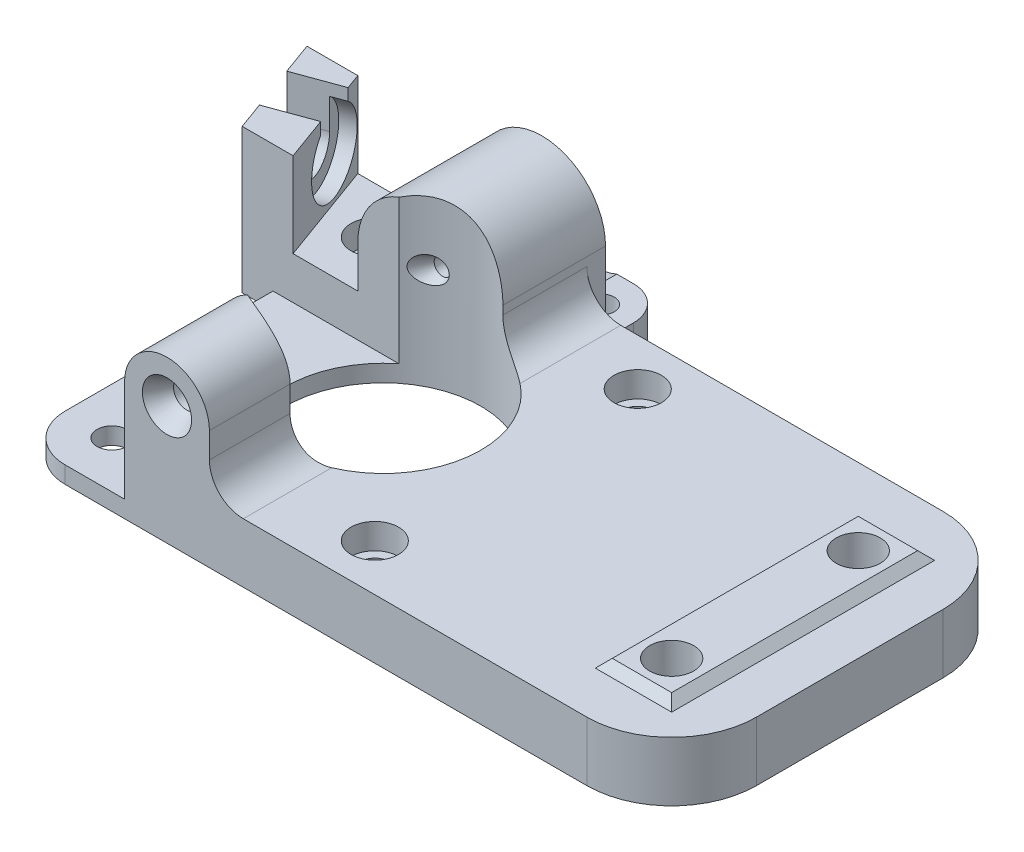
from build123d import *

# Parameters (mm, degrees)
SKETCH1_W                = 77
SKETCH1_H                = 42
BOSS_EXTRUDE1_DEPTH      = 7
FILLET1_R                = 10
FILLET2_R                = 10
FILLET3_R                = 5.5
SKETCH2_W                = 9
SKETCH2_H                = 31
BOSS_EXTRUDE2_DEPTH      = 1
CUT_EXTRUDE1_DEPTH       = 11
CUT_EXTRUDE2_DEPTH       = 31
SKETCH5_R                = 2.6
CUT_EXTRUDE3_DEPTH       = 6
SKETCH6_R                = 2.8
CUT_EXTRUDE4_DEPTH       = 3
SKETCH7_R                = 1.75
CUT_EXTRUDE5_DEPTH       = 4
SKETCH8_W                = 14.5
SKETCH8_H                = 30
CUT_EXTRUDE6_DEPTH       = 5
BOSS_EXTRUDE3_DEPTH      = 11.5
BOSS_EXTRUDE4_DEPTH      = 4
BOSS_EXTRUDE5_DEPTH      = 14.2
FILLET4_R                = 4
FILLET5_R                = 4
SKETCH12_R               = 11.5
CUT_EXTRUDE7_DEPTH       = 14
CUT_EXTRUDE7_DEPTH_BACK  = 14
SKETCH13_W               = 6.185296294
SKETCH13_H               = 18.5
CUT_EXTRUDE8_DEPTH       = 14
BOSS_EXTRUDE6_DEPTH      = 10
BOSS_EXTRUDE6_DEPTH_BACK = 7
CUT_EXTRUDE9_DEPTH       = 10
SKETCH16_R               = 4.85
CUT_EXTRUDE10_DEPTH      = 10
SKETCH17_R               = 1
CUT_EXTRUDE11_DEPTH      = 5
SKETCH19_R               = 2.8
CUT_EXTRUDE12_DEPTH      = 3
SKETCH20_R               = 1.75
CUT_EXTRUDE13_DEPTH      = 8
SKETCH21_R               = 4.5
CUT_EXTRUDE14_DEPTH      = 1.7
CUT_EXTRUDE15_DEPTH      = 1.7
CUT_EXTRUDE15_DEPTH_BACK = 31.7
SKETCH23_R               = 1.75
CUT_EXTRUDE16_DEPTH      = 50.7
SKETCH24_R               = 2.9
CUT_EXTRUDE17_DEPTH      = 2.325
CUT_EXTRUDE17_TAPER      = 30
CUT_EXTRUDE18_REACH      = 49.675
SKETCH25_R               = 1.557660624
SKETCH26_R               = 7
CUT_EXTRUDE19_DEPTH      = 5.8
SKETCH27_R               = 1.5
CUT_EXTRUDE20_DEPTH      = 5.0000001
SKETCH29_R               = 5
CUT_EXTRUDE21_DEPTH      = 2
MIRROR5_COPY_1_SKETCH_R  = 2.6
MIRROR5_COPY_1_DEPTH     = 6
MIRROR5_COPY_2_SKETCH_R  = 2.6
MIRROR5_COPY_2_DEPTH     = 6
SKETCH35_R               = 1
CUT_EXTRUDE23_DEPTH      = 2.3
CUT_EXTRUDE23_TAPER      = -28


with BuildPart() as part:
    # Sketch1 → Boss-Extrude1 (new body)
    with BuildSketch(Plane(origin=(0, 0, 0), x_dir=(1, 0, 0), z_dir=(0, 1, 0))):
        with Locations((38.5, 21)):
            Rectangle(SKETCH1_W, SKETCH1_H)
    extrude(amount=BOSS_EXTRUDE1_DEPTH)

    # Fillet1
    fillet1_edges = [part.edges().sort_by_distance(p)[0] for p in [
        (77, 3.5, 0),
    ]]
    fillet(fillet1_edges, radius=FILLET1_R)

    # Fillet2
    fillet2_edges = [part.edges().sort_by_distance(p)[0] for p in [
        (77, 3.5, -42),
    ]]
    fillet(fillet2_edges, radius=FILLET2_R)

    # Fillet3
    fillet3_edges = [part.edges().sort_by_distance(p)[0] for p in [
        (0, 3.5, 0),
    ]]
    fillet(fillet3_edges, radius=FILLET3_R)

    # Sketch2 → Boss-Extrude2 (add)
    with BuildSketch(Plane(origin=(0, 7, 0), x_dir=(1, 0, 0), z_dir=(0, 1, 0))):
        with Locations((67, 21)):
            Rectangle(SKETCH2_W, SKETCH2_H)
    extrude(amount=BOSS_EXTRUDE2_DEPTH)

    # Sketch3 → Cut-Extrude1 (cut)
    with BuildSketch(Plane(origin=(71.5, 0, 0), x_dir=(0, 0, -1), z_dir=(1, 0, 0))):
        Polygon((5.5, 7), (5.5, 8), (6.5, 8), align=None)
    cut_extrude1 = extrude(amount=-CUT_EXTRUDE1_DEPTH, mode=Mode.SUBTRACT)

    # Sketch4 → Cut-Extrude2 (cut)
    with BuildSketch(Plane(origin=(0, 0, -36.5), x_dir=(-1, 0, 0), z_dir=(0, 0, -1))):
        Polygon((-71.5, 8), (-70.5, 8), (-71.5, 7), align=None)
        Polygon((-62.5, 8), (-62.5, 7), (-63.5, 8), align=None)
    extrude(amount=-CUT_EXTRUDE2_DEPTH, mode=Mode.SUBTRACT)

    # Mirror2: Cut-Extrude1 across plane
    add(cut_extrude1.mirror(Plane.XY.offset(-21)), mode=Mode.SUBTRACT)

    # Sketch5 → Cut-Extrude3 (cut)
    with BuildSketch(Plane(origin=(0, 8, 0), x_dir=(1, 0, 0), z_dir=(0, 1, 0))):
        with Locations((67, 10)):
            Circle(SKETCH5_R)
    cut_extrude3 = extrude(amount=-CUT_EXTRUDE3_DEPTH, mode=Mode.SUBTRACT)

    # Mirror3: Cut-Extrude3 across plane
    add(cut_extrude3.mirror(Plane.XY.offset(-21)), mode=Mode.SUBTRACT)

    # Sketch6 → Cut-Extrude4 (cut)
    with BuildSketch(Plane(origin=(0, 7, 0), x_dir=(1, 0, 0), z_dir=(0, 1, 0))):
        with Locations((36.5, 5.5)):
            Circle(SKETCH6_R)
    cut_extrude4 = extrude(amount=-CUT_EXTRUDE4_DEPTH, mode=Mode.SUBTRACT)

    # Sketch7 → Cut-Extrude5 (cut)
    with BuildSketch(Plane(origin=(0, 4, 0), x_dir=(1, 0, 0), z_dir=(0, 1, 0))):
        with Locations((36.5, 5.5)):
            Circle(SKETCH7_R)
    cut_extrude5 = extrude(amount=-CUT_EXTRUDE5_DEPTH, mode=Mode.SUBTRACT)

    # Mirror4: Cut-Extrude4, Cut-Extrude5 across plane
    add(cut_extrude4.mirror(Plane.XY.offset(-21)), mode=Mode.SUBTRACT)
    add(cut_extrude5.mirror(Plane.XY.offset(-21)), mode=Mode.SUBTRACT)

    # Sketch8 → Cut-Extrude6 (cut)
    with BuildSketch(Plane(origin=(0, 7, 0), x_dir=(1, 0, 0), z_dir=(0, 1, 0))):
        with Locations((7.25, 15)):
            Rectangle(SKETCH8_W, SKETCH8_H)
    extrude(amount=-CUT_EXTRUDE6_DEPTH, mode=Mode.SUBTRACT)

    # Sketch9 → Boss-Extrude3 (add)
    with BuildSketch(Plane.XY):
        with BuildLine():
            Line((12.5, 2), (12.5, 14))
            ThreePointArc((12.5, 14), (17.5, 19), (22.5, 14))
            Line((22.5, 14), (22.5, 7))
            Line((22.5, 7), (14.5, 7))
            Line((14.5, 7), (14.5, 2))
            Line((14.5, 2), (12.5, 2))
        make_face()
    extrude(amount=-BOSS_EXTRUDE3_DEPTH)

    # Sketch10 → Boss-Extrude4 (add)
    with BuildSketch(Plane.XZ):
        with BuildLine():
            Line((26.5, -42), (26.5, -46))
            ThreePointArc((26.5, -46), (25.328427125, -48.828427125), (22.5, -50))
            Line((22.5, -50), (12.5, -50))
            ThreePointArc((12.5, -50), (9.671572875, -48.828427125), (8.5, -46))
            Line((8.5, -46), (8.5, -42))
            Line((8.5, -42), (26.5, -42))
        make_face()
    extrude(amount=-BOSS_EXTRUDE4_DEPTH)

    # Sketch11 → Boss-Extrude5 (add)
    with BuildSketch(Plane(origin=(0, 0, -44.2), x_dir=(-1, 0, 0), z_dir=(0, 0, -1))):
        with BuildLine():
            Line((-25, 4), (-25, 12))
            ThreePointArc((-25, 12), (-17.5, 19.5), (-10, 12))
            Line((-10, 12), (-10, 4))
            Line((-10, 4), (-25, 4))
        make_face()
    extrude(amount=-BOSS_EXTRUDE5_DEPTH)

    # Fillet4
    fillet4_edges = [part.edges().sort_by_distance(p)[0] for p in [
        (22.5, 7, -5.75),
    ]]
    fillet(fillet4_edges, radius=FILLET4_R)

    # Fillet5
    fillet5_edges = [part.edges().sort_by_distance(p)[0] for p in [
        (25, 7, -36),
    ]]
    fillet(fillet5_edges, radius=FILLET5_R)

    # Sketch12 → Cut-Extrude7 (cut, two sides)
    with BuildSketch(Plane(origin=(0, 7, 0), x_dir=(1, 0, 0), z_dir=(0, 1, 0))) as cut_extrude7_sk:
        with Locations((22, 21)):
            Circle(SKETCH12_R)
    extrude(amount=CUT_EXTRUDE7_DEPTH, mode=Mode.SUBTRACT)
    extrude(cut_extrude7_sk.sketch, amount=-CUT_EXTRUDE7_DEPTH_BACK, mode=Mode.SUBTRACT)

    # Sketch13 → Cut-Extrude8 (cut)
    with BuildSketch(Plane(origin=(0, 2, 0), x_dir=(1, 0, 0), z_dir=(0, 1, 0))):
        with Locations((14.723239075, 20.75)):
            Rectangle(SKETCH13_W, SKETCH13_H)
    extrude(amount=CUT_EXTRUDE8_DEPTH, mode=Mode.SUBTRACT)

    # Sketch14 → Boss-Extrude6 (add, two sides)
    with BuildSketch(Plane(origin=(0, 7, 0), x_dir=(1, 0, 0), z_dir=(0, 1, 0))) as boss_extrude6_sk:
        Polygon((10, 42), (-8, 42), (-3.632357189, 30), (10, 30), align=None)
    extrude(amount=BOSS_EXTRUDE6_DEPTH)
    extrude(boss_extrude6_sk.sketch, amount=-BOSS_EXTRUDE6_DEPTH_BACK)

    # Sketch15 → Cut-Extrude9 (cut)
    with BuildSketch(Plane(origin=(0, 17, 0), x_dir=(1, 0, 0), z_dir=(0, 1, 0))):
        Polygon((10, 42), (10, 30), (2.367642811, 30), (-2, 42), align=None)
    extrude(amount=-CUT_EXTRUDE9_DEPTH, mode=Mode.SUBTRACT)

    # Sketch16 → Cut-Extrude10 (cut)
    with BuildSketch(Plane(origin=(0, 0, -44.2), x_dir=(-1, 0, 0), z_dir=(0, 0, -1))):
        with Locations((-17.5, 12)):
            Circle(SKETCH16_R)
    extrude(amount=-CUT_EXTRUDE10_DEPTH, mode=Mode.SUBTRACT)

    # Sketch17 → Cut-Extrude11 (cut)
    with BuildSketch(Plane(origin=(0, 0, -34.2), x_dir=(-1, 0, 0), z_dir=(0, 0, -1))):
        with Locations((-17.5, 12)):
            Circle(SKETCH17_R)
    extrude(amount=-CUT_EXTRUDE11_DEPTH, mode=Mode.SUBTRACT)

    # Sketch19 → Cut-Extrude12 (cut)
    with BuildSketch(Plane(origin=(0, 7, 0), x_dir=(1, 0, 0), z_dir=(0, 1, 0))):
        with Locations((5.5, 36.5)):
            Circle(SKETCH19_R)
    extrude(amount=-CUT_EXTRUDE12_DEPTH, mode=Mode.SUBTRACT)

    # Sketch20 → Cut-Extrude13 (cut)
    with BuildSketch(Plane(origin=(0, 4, 0), x_dir=(1, 0, 0), z_dir=(0, 1, 0))):
        with Locations((5.5, 36.5)):
            Circle(SKETCH20_R)
    extrude(amount=-CUT_EXTRUDE13_DEPTH, mode=Mode.SUBTRACT)

    # Sketch21 → Cut-Extrude14 (cut)
    with BuildSketch(Plane(origin=(11.73249536, 0, -4.270279085), x_dir=(-0.342020143, 0, -0.939692621), z_dir=(0.939692621, 0, -0.342020143))):
        with Locations((35.53099709, 12)):
            Circle(SKETCH21_R)
    extrude(amount=-CUT_EXTRUDE14_DEPTH, mode=Mode.SUBTRACT)

    # Sketch22 → Cut-Extrude15 (cut, two sides)
    with BuildSketch(Plane(origin=(10.135017905, 0, -3.688844841), x_dir=(-0.342020143, 0, -0.939692621), z_dir=(0.939692621, 0, -0.342020143))) as cut_extrude15_sk:
        with BuildLine():
            Line((32.83099709, 12), (32.83099709, 17))
            Line((32.83099709, 17), (38.23099709, 17))
            Line((38.23099709, 17), (38.23099709, 12))
            ThreePointArc((38.23099709, 12), (35.53099709, 9.3), (32.83099709, 12))
        make_face()
    extrude(amount=CUT_EXTRUDE15_DEPTH, mode=Mode.SUBTRACT)
    extrude(cut_extrude15_sk.sketch, amount=-CUT_EXTRUDE15_DEPTH_BACK, mode=Mode.SUBTRACT)

    # Sketch23 → Cut-Extrude16 (cut)
    with BuildSketch(Plane(origin=(0, 2, 0), x_dir=(1, 0, 0), z_dir=(0, 1, 0))):
        with Locations((5.5, 5.5)):
            Circle(SKETCH23_R)
    extrude(amount=-CUT_EXTRUDE16_DEPTH, mode=Mode.SUBTRACT)

    # Sketch24 → Cut-Extrude17 (cut)
    with BuildSketch(Plane.XY):
        with Locations((17.5, 14)):
            Circle(SKETCH24_R)
    extrude(amount=-CUT_EXTRUDE17_DEPTH, taper=CUT_EXTRUDE17_TAPER, mode=Mode.SUBTRACT)

    # Sketch25 → Cut-Extrude18 (cut, up to next)
    with BuildSketch(Plane.XY.offset(-2.325), mode=Mode.PRIVATE) as cut_extrude18_sk1:
        with Locations((17.5, 14)):
            Circle(SKETCH25_R)
    cut_extrude18_tool1 = extrude(cut_extrude18_sk1.sketch, amount=-CUT_EXTRUDE18_REACH, mode=Mode.PRIVATE) & part.part
    add(cut_extrude18_tool1.solids().sort_by_distance((17.5, 14, -2.325))[0], mode=Mode.SUBTRACT)

    # Sketch26 → Cut-Extrude19 (cut)
    with BuildSketch(Plane(origin=(0, 0, -50), x_dir=(-1, 0, 0), z_dir=(0, 0, -1))):
        with Locations((-17.699941677, 10.4)):
            Circle(SKETCH26_R)
    extrude(amount=-CUT_EXTRUDE19_DEPTH, mode=Mode.SUBTRACT)

    # Sketch27 → Cut-Extrude20 (cut, through all)
    with BuildSketch(Plane(origin=(0, 4, 0), x_dir=(1, 0, 0), z_dir=(0, 1, 0))):
        with Locations((22.735431052, 46)):
            Circle(SKETCH27_R)
        with Locations((12.664452301, 46)):
            Circle(SKETCH27_R)
    extrude(amount=-CUT_EXTRUDE20_DEPTH, mode=Mode.SUBTRACT)

    # Sketch29 → Cut-Extrude21 (cut)
    with BuildSketch(Plane(origin=(0, 0, 0), x_dir=(-1, 0, 0), z_dir=(0, -1, 0))):
        with Locations((-67, 32)):
            Circle(SKETCH29_R)
    cut_extrude21 = extrude(amount=-CUT_EXTRUDE21_DEPTH, mode=Mode.SUBTRACT)

    # Mirror5: Cut-Extrude21 across plane
    add(cut_extrude21.mirror(Plane.XY.offset(-21)), mode=Mode.SUBTRACT)

    # Mirror5 copy 1 sketch → Mirror5 copy 1 (cut)
    with BuildSketch(Plane(origin=(0, 8, 0), x_dir=(1, 0, 0), z_dir=(0, 1, 0))):
        with Locations((67, 10)):
            Circle(MIRROR5_COPY_1_SKETCH_R)
    extrude(amount=-MIRROR5_COPY_1_DEPTH, mode=Mode.SUBTRACT)

    # Mirror5 copy 2 sketch → Mirror5 copy 2 (cut)
    with BuildSketch(Plane(origin=(0, 8, -42), x_dir=(1, 0, 0), z_dir=(0, 1, 0))):
        with Locations((67, -10)):
            Circle(MIRROR5_COPY_2_SKETCH_R)
    extrude(amount=-MIRROR5_COPY_2_DEPTH, mode=Mode.SUBTRACT)

    # Sketch35 → Cut-Extrude23 (cut)
    with BuildSketch(Plane.XY.offset(-32.5)):
        with Locations((17.5, 12)):
            Circle(SKETCH35_R)
    extrude(amount=CUT_EXTRUDE23_DEPTH, taper=CUT_EXTRUDE23_TAPER, mode=Mode.SUBTRACT)


solid = part.part
